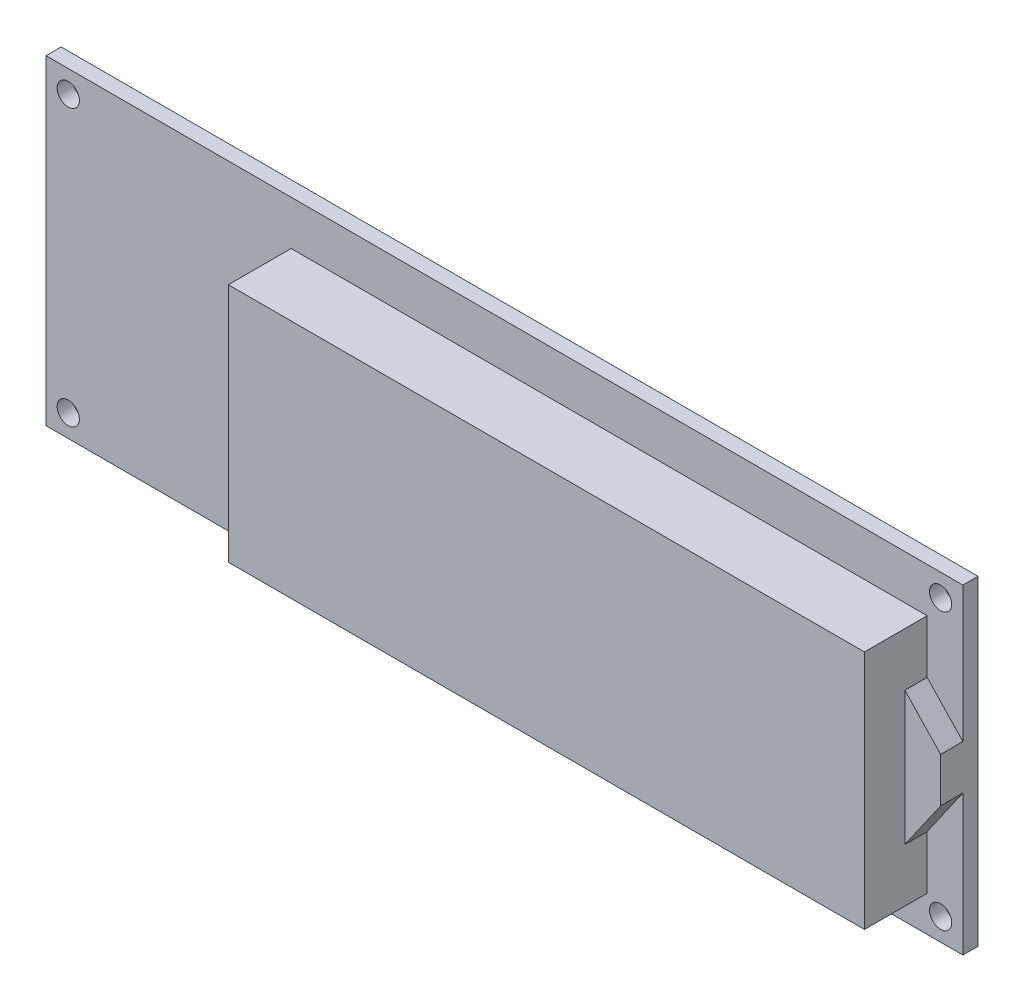
from build123d import *

# Parameters (mm, degrees)
CROQUIS1_W              = 103
CROQUIS1_H              = 36
SALIENTE_EXTRUIR1_DEPTH = 1.7
CROQUIS2_W              = 71.45
CROQUIS2_H              = 27
SALIENTE_EXTRUIR2_DEPTH = 7.05
CROQUIS3_R              = 1.25
CORTAR_EXTRUIR1_DEPTH   = 6
SALIENTE_EXTRUIR3_DEPTH = 2.5


with BuildPart() as part:
    # Croquis1 → Saliente-Extruir1 (new body)
    with BuildSketch(Plane.XY):
        Rectangle(CROQUIS1_W, CROQUIS1_H)
    extrude(amount=SALIENTE_EXTRUIR1_DEPTH)

    # Croquis2 → Saliente-Extruir2 (add)
    with BuildSketch(Plane.XY.offset(1.7)):
        with Locations((11.765, -0.49)):
            Rectangle(CROQUIS2_W, CROQUIS2_H)
    extrude(amount=SALIENTE_EXTRUIR2_DEPTH)

    # Croquis3 → Cortar-Extruir1 (cut)
    with BuildSketch(Plane.XY.offset(1.7)):
        with Locations((-49, 15.5)):
            Circle(CROQUIS3_R)
        with Locations((-49, -15.5)):
            Circle(CROQUIS3_R)
        with Locations((49, 15.5)):
            Circle(CROQUIS3_R)
        with Locations((49, -15.5)):
            Circle(CROQUIS3_R)
    extrude(amount=-CORTAR_EXTRUIR1_DEPTH, mode=Mode.SUBTRACT)

    # Croquis4 → Saliente-Extruir3 (add)
    with BuildSketch(Plane.XY.offset(1.7)):
        Polygon((47.49, 7.01), (51.5, 2.775802991), (51.5, -2.234197009), (47.49, -7.99), align=None)
    extrude(amount=SALIENTE_EXTRUIR3_DEPTH)


solid = part.part
